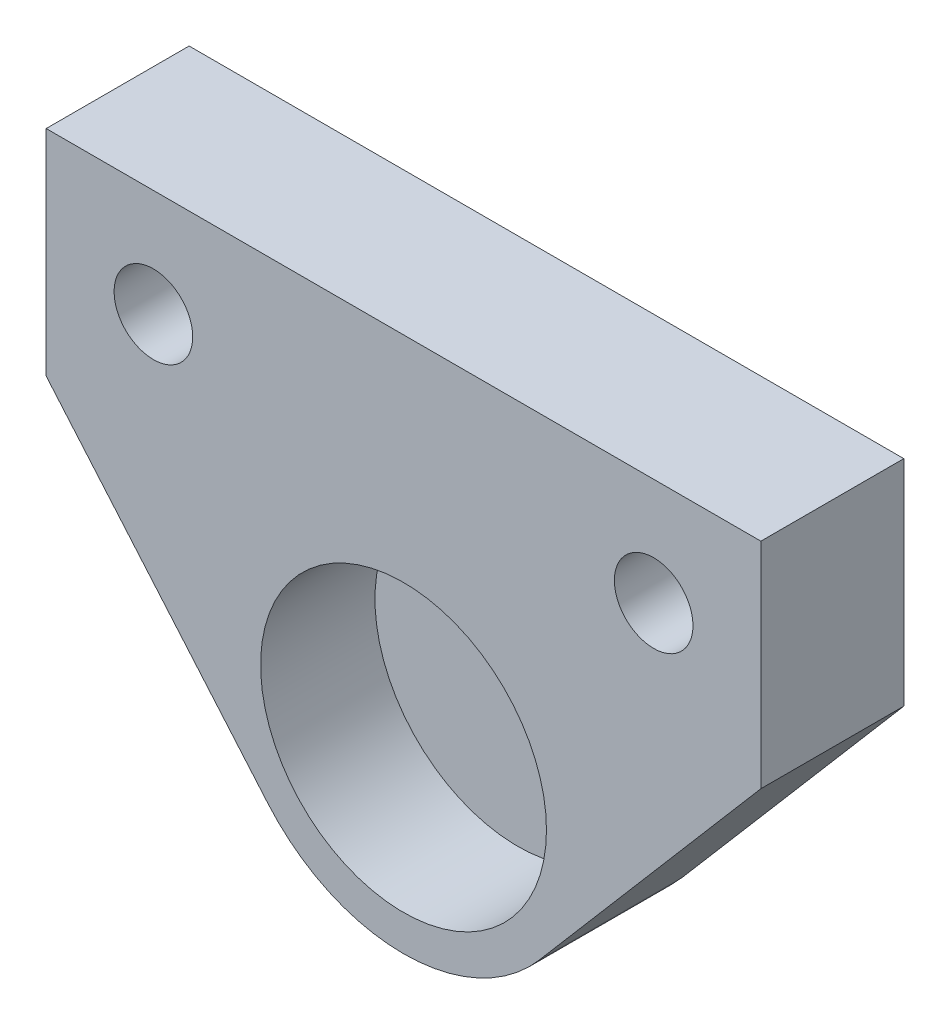
from build123d import *

# Parameters (mm, degrees)
AUFSATZ_LINEAR_AUSTRAGEN1_DEPTH                      = 10
SKIZZE2_R                                            = 10
SCHNITT_LINEAR_AUSTRAGEN1_DEPTH                      = 8
FORMSENKUNG_F_R_M5_SENKSCHRAUBE_MIT_INNE_D           = 5.5
FORMSENKUNG_F_R_M5_SENKSCHRAUBE_MIT_INNE_DEPTH       = 10
FORMSENKUNG_F_R_M5_SENKSCHRAUBE_MIT_INNE_CSINK_D     = 11.47
FORMSENKUNG_F_R_M5_SENKSCHRAUBE_MIT_INNE_CSINK_ANGLE = 90


with BuildPart() as part:
    # Skizze1 → Aufsatz-Linear austragen1 (new body)
    with BuildSketch(Plane.XY):
        with BuildLine():
            Line((-9.499737937, -8.124344843), (-25, 10))
            Line((-25, 10), (-25, 25))
            Line((-25, 25), (25, 25))
            Line((25, 25), (25, 10))
            Line((25, 10), (9.499737937, -8.124344843))
            ThreePointArc((9.499737937, -8.124344843), (0, -12.5), (-9.499737937, -8.124344843))
        make_face()
    extrude(amount=AUFSATZ_LINEAR_AUSTRAGEN1_DEPTH)

    # Skizze2 → Schnitt-Linear austragen1 (cut)
    with BuildSketch(Plane.XY.offset(10)):
        Circle(SKIZZE2_R)
    extrude(amount=-SCHNITT_LINEAR_AUSTRAGEN1_DEPTH, mode=Mode.SUBTRACT)

    # Formsenkung für M5 Senkschraube mit Innensechskant1
    with Locations(Plane(origin=(0, 0, 0), x_dir=(-1, 0, 0), z_dir=(0, 0, -1))):
        with Locations((-17.5, 17.499100788), (17.5, 17.499100788)):
            CounterSinkHole(FORMSENKUNG_F_R_M5_SENKSCHRAUBE_MIT_INNE_D / 2, FORMSENKUNG_F_R_M5_SENKSCHRAUBE_MIT_INNE_CSINK_D / 2, depth=FORMSENKUNG_F_R_M5_SENKSCHRAUBE_MIT_INNE_DEPTH, counter_sink_angle=FORMSENKUNG_F_R_M5_SENKSCHRAUBE_MIT_INNE_CSINK_ANGLE)


solid = part.part
